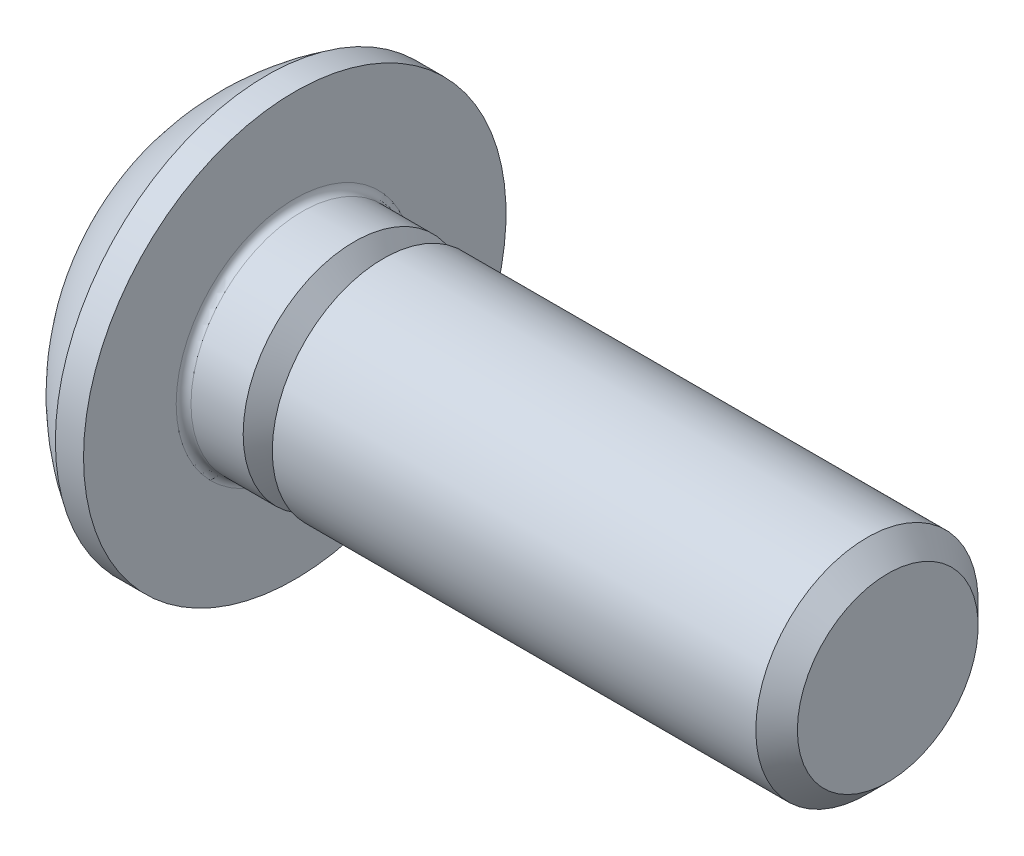
from build123d import *

# Parameters (mm, degrees)
FILLET1_R   = 0.1
HEX_2_DEPTH = 1.04


with BuildPart() as part:
    # BodySke → BaseBody (revolve)
    with BuildSketch(Plane.XY):
        with BuildLine():
            Line((9.65, 0), (9.65, 1.2195))
            Line((9.65, 1.2195), (9.3695, 1.5))
            Line((9.3695, 1.5), (1.65, 1.5))
            Line((1.65, 1.5), (1.65, 2.85))
            Line((1.65, 2.85), (1.27, 2.85))
            ThreePointArc((1.27, 2.85), (0.53140404, 2.229827628), (0, 1.425))
            Line((0, 1.425), (0, 0))
            Line((0, 0), (9.65, 0))
        make_face()
    revolve(axis=Axis((0, 0, 0), (1, 0, 0)))

    # Fillet1
    fillet1_edges = [part.edges().sort_by_distance(p)[0] for p in [
        (1.65, -1.5, 0),
    ]]
    fillet(fillet1_edges, radius=FILLET1_R)

    # Sketch2 → PreBroach (revolve, cut)
    with BuildSketch(Plane.XY):
        Polygon((0, 1), (1.04, 1), (1.617350269, 0), (0, 0), align=None)
    revolve(axis=Axis((0, 0, 0), (1, 0, 0)), mode=Mode.SUBTRACT)

    # Sketch3 → Hex 2 (cut)
    with BuildSketch(Plane(origin=(0, 0, 0), x_dir=(0, 0, -1), z_dir=(1, 0, 0))):
        Polygon((-1, -0.577350269), (-1, 0.577350269), (0, 1.154700538), (1, 0.577350269), (1, -0.577350269), (0, -1.154700538), align=None)
    extrude(amount=HEX_2_DEPTH, mode=Mode.SUBTRACT)

    # ThdSchSke → ThreadSchematic (revolve, cut)
    with BuildSketch(Plane.XY):
        Polygon((2.65, -1.2195), (2.453591786, -1.5), (2.453591786, -1.875), (2.846408214, -1.875), (2.846408214, -1.5), align=None)
    revolve(axis=Axis((-3.175, 0, 0), (1, 0, 0)), mode=Mode.SUBTRACT)


solid = part.part
